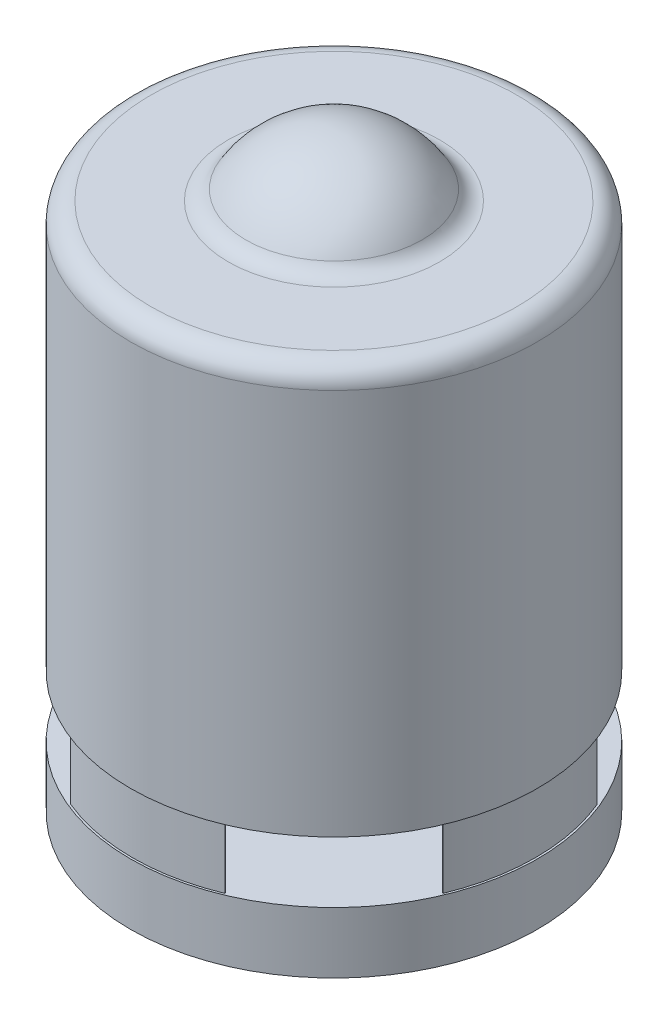
from build123d import *

# Parameters (mm, degrees)
SKETCH1_R           = 100
BOSS_EXTRUDE1_DEPTH = 30
BOSS_EXTRUDE2_DEPTH = 30
SKETCH3_R           = 100
BOSS_EXTRUDE3_DEPTH = 200
FILLET1_R           = 10
SCALE1_SCALE        = 0.233333333


with BuildPart() as part:
    # Sketch1 → Boss-Extrude1 (new body)
    with BuildSketch(Plane(origin=(0, 0, 0), x_dir=(1, 0, 0), z_dir=(0, 1, 0))):
        Circle(SKETCH1_R)
    extrude(amount=BOSS_EXTRUDE1_DEPTH)

    # Sketch2 → Boss-Extrude2 (add)
    with BuildSketch(Plane(origin=(0, 30, 0), x_dir=(1, 0, 0), z_dir=(0, 1, 0))):
        with BuildLine():
            Line((91.464073719, 37.885659804), (91.002133952, 37.694318088))
            ThreePointArc((91.002133952, 37.694318088), (98.5, 0), (91.002133952, -37.694318088))
            Line((91.002133952, -37.694318088), (91.464073719, -37.885659804))
            ThreePointArc((91.464073719, -37.885659804), (99, 0), (91.464073719, 37.885659804))
        make_face()
        with BuildLine():
            Line((37.885659804, -91.464073719), (37.694318088, -91.002133952))
            ThreePointArc((37.694318088, -91.002133952), (0, -98.5), (-37.694318088, -91.002133952))
            Line((-37.694318088, -91.002133952), (-37.885659804, -91.464073719))
            ThreePointArc((-37.885659804, -91.464073719), (0, -99), (37.885659804, -91.464073719))
        make_face()
        with BuildLine():
            Line((-91.464073719, -37.885659804), (-91.002133952, -37.694318088))
            ThreePointArc((-91.002133952, -37.694318088), (-98.5, 0), (-91.002133952, 37.694318088))
            Line((-91.002133952, 37.694318088), (-91.464073719, 37.885659804))
            ThreePointArc((-91.464073719, 37.885659804), (-99, 0), (-91.464073719, -37.885659804))
        make_face()
        with BuildLine():
            Line((-37.885659804, 91.464073719), (-37.694318088, 91.002133952))
            ThreePointArc((-37.694318088, 91.002133952), (0, 98.5), (37.694318088, 91.002133952))
            Line((37.694318088, 91.002133952), (37.885659804, 91.464073719))
            ThreePointArc((37.885659804, 91.464073719), (0, 99), (-37.885659804, 91.464073719))
        make_face()
    extrude(amount=BOSS_EXTRUDE2_DEPTH)

    # Sketch3 → Boss-Extrude3 (add)
    with BuildSketch(Plane(origin=(0, 60, 0), x_dir=(1, 0, 0), z_dir=(0, 1, 0))):
        Circle(SKETCH3_R)
    extrude(amount=BOSS_EXTRUDE3_DEPTH)

    # Sketch5 → Revolve1 (revolve)
    with BuildSketch(Plane.XY):
        with BuildLine():
            Line((45.82575695, 260), (0, 260))
            Line((0, 260), (0, 290))
            ThreePointArc((0, 290), (27.386127875, 281.833001327), (45.82575695, 260))
        make_face()
    revolve(axis=Axis((0, 115.728499237, 0), (0, 1, 0)))

    # Fillet1
    fillet1_edges = [part.edges().sort_by_distance(p)[0] for p in [
        (-100, 260, 0),
        (-45.82575695, 260, 0),
    ]]
    fillet(fillet1_edges, radius=FILLET1_R)


with BuildPart() as part_1:
    # Scale1: scaled about (-2.1e-08, 142.843087279, 0)
    add(part.part.scale(SCALE1_SCALE).moved(Location((-1.6e-08, 109.513033581, 0))))


solid = part_1.part
